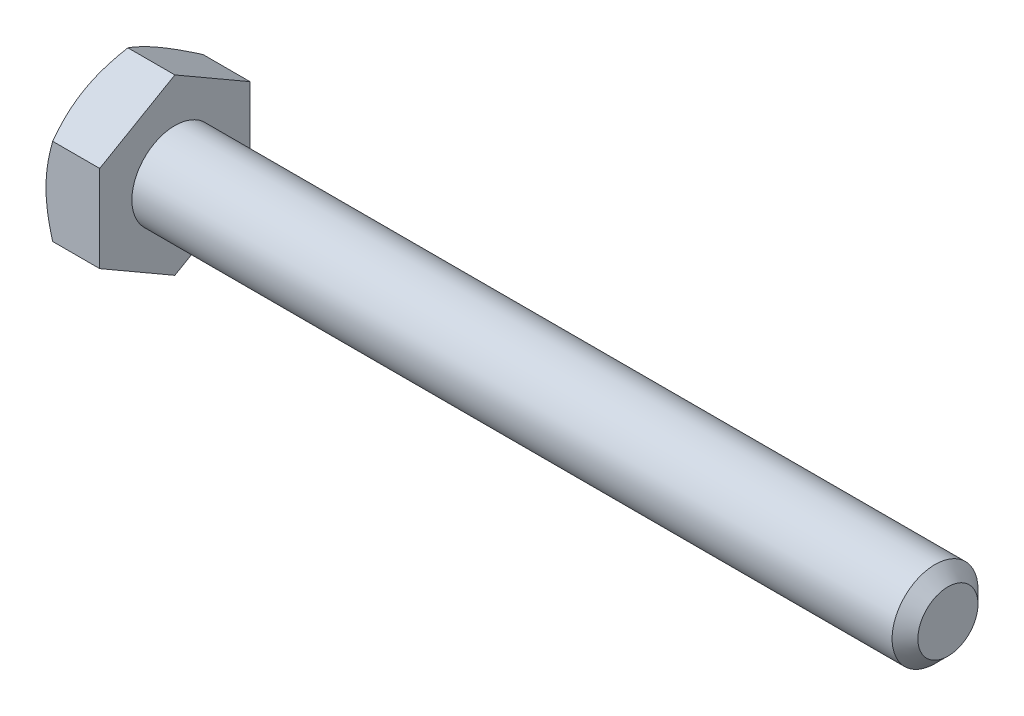
from build123d import *

# Parameters (mm, degrees)
SKETCH5_R           = 3.175
BOSS_EXTRUDE3_DEPTH = 57.15
CHAMFER1_SIZE       = 0.9525
BOSS_EXTRUDE4_DEPTH = 3.96875
SKETCH8_OUTSIDE_W   = 240.984
SKETCH8_OUTSIDE_H   = 242.704
SKETCH8_OUTSIDE_R   = 5.55625
CUT_EXTRUDE3_DEPTH  = 62.11875
CUT_EXTRUDE3_TAPER  = 60
CUT_EXTRUDE4_DEPTH  = 0.254
CIRPATTERN1_COUNT   = 3


with BuildPart() as part:
    # Sketch5 → Boss-Extrude3 (new body)
    with BuildSketch(Plane(origin=(30.559375, 0, 0), x_dir=(0, 0, -1), z_dir=(1, 0, 0))):
        Circle(SKETCH5_R)
    extrude(amount=-BOSS_EXTRUDE3_DEPTH)

    # Chamfer1
    chamfer1_edges = [part.edges().sort_by_distance(p)[0] for p in [
        (30.559375, 0, 3.175),
    ]]
    chamfer(chamfer1_edges, length=CHAMFER1_SIZE)

    # Sketch11 → Revolve1 (revolve)
    with BuildSketch(Plane.XY):
        Polygon((-26.590625, 3.175), (-26.590625, 0), (14.684375, 0), (11.509375, 3.175), align=None)
    revolve(axis=Axis((-26.590625, 0, 0), (1, 0, 0)))

    # Sketch6 → Boss-Extrude4 (add)
    with BuildSketch(Plane.ZY.offset(26.590625)):
        Polygon((5.55625, 3.207902433), (0, 6.415804866), (-5.55625, 3.207902433), (-5.55625, -3.207902433), (0, -6.415804866), (5.55625, -3.207902433), align=None)
    extrude(amount=BOSS_EXTRUDE4_DEPTH)

    # Sketch8 outside → Cut-Extrude3 (cut, through all)
    with BuildSketch(Plane.ZY.offset(30.559375)):
        Rectangle(SKETCH8_OUTSIDE_W, SKETCH8_OUTSIDE_H)
        Circle(SKETCH8_OUTSIDE_R, mode=Mode.SUBTRACT)
    extrude(amount=-CUT_EXTRUDE3_DEPTH, taper=CUT_EXTRUDE3_TAPER, mode=Mode.SUBTRACT)

    # Sketch12 → Cut-Extrude4 (cut)
    with BuildSketch(Plane.ZY.offset(30.559375)):
        with BuildLine():
            Line((0.1666875, 4.2783125), (0.1666875, 2.3891875))
            ThreePointArc((0.1666875, 2.3891875), (0, 2.2225), (-0.1666875, 2.3891875))
            Line((-0.1666875, 2.3891875), (-0.1666875, 4.2783125))
            ThreePointArc((-0.1666875, 4.2783125), (0, 4.445), (0.1666875, 4.2783125))
        make_face()
    cut_extrude4 = extrude(amount=-CUT_EXTRUDE4_DEPTH, mode=Mode.SUBTRACT)

    # CirPattern1: Cut-Extrude4 ×3 about axis
    cirpattern1_axis = Axis((0, 0, 0), (1, 0, 0))
    for i in range(1, CIRPATTERN1_COUNT):
        add(cut_extrude4.rotate(cirpattern1_axis, i * 360 / CIRPATTERN1_COUNT), mode=Mode.SUBTRACT)


solid = part.part
